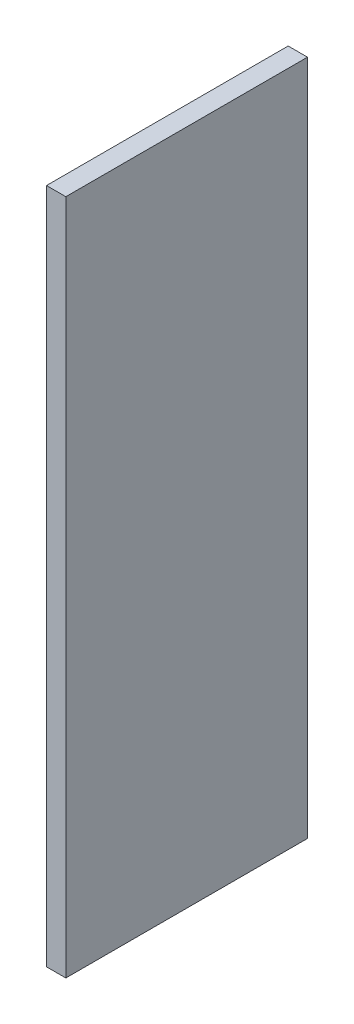
from build123d import *

# Parameters (mm, degrees)
SKETCH1_W           = 0.4
SKETCH1_H           = 14
BOSS_EXTRUDE1_DEPTH = 5


with BuildPart() as part:
    # Sketch1 → Boss-Extrude1 (new body)
    with BuildSketch(Plane.XY):
        with Locations((0.2, 7)):
            Rectangle(SKETCH1_W, SKETCH1_H)
    extrude(amount=BOSS_EXTRUDE1_DEPTH)


solid = part.part
